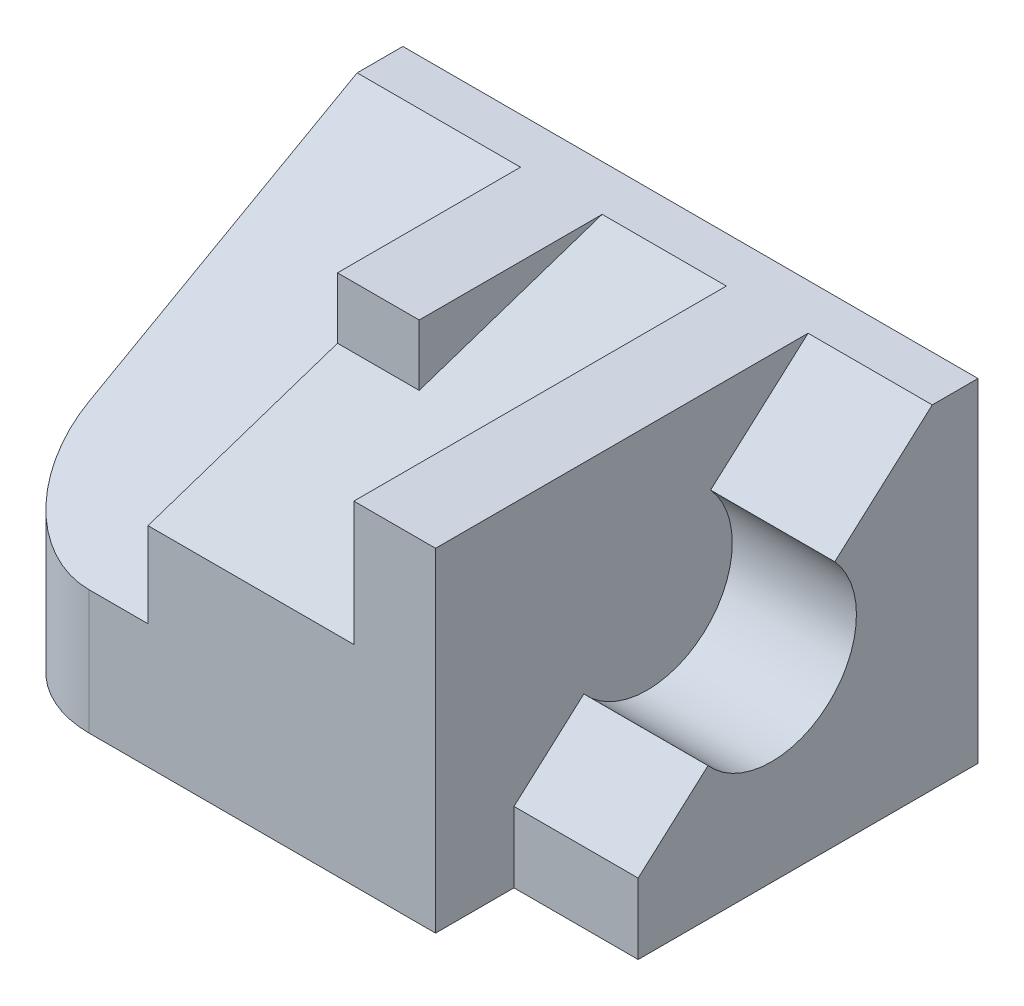
from build123d import *

# Parameters (mm, degrees)
BOSS_EXTRUDE1_DEPTH = 25.5
CUT_EXTRUDE1_DEPTH  = 12.5
CUT_EXTRUDE2_DEPTH  = 15.75
BOSS_EXTRUDE2_REACH = 27.5
SKETCH2_W           = 6.25
SKETCH2_H           = 14
CUT_EXTRUDE3_DEPTH  = 9.5
FILLET1_R           = 8


with BuildPart() as part:
    # Sketch1 → Boss-Extrude1 (new body)
    with BuildSketch(Plane(origin=(0, 0, 0), x_dir=(1, 0, 0), z_dir=(0, 1, 0))):
        Polygon((0, 0), (44, 0), (44, -26), (34.5, -26), (34.5, -32), (0, -32), align=None)
    extrude(amount=BOSS_EXTRUDE1_DEPTH)

    # Sketch3 → Cut-Extrude1 (cut)
    with BuildSketch(Plane.ZY):
        Polygon((32, 25.5), (3.5, 25.5), (32, 9.5), align=None)
    extrude(amount=-CUT_EXTRUDE1_DEPTH, mode=Mode.SUBTRACT)

    # Sketch4 → Cut-Extrude2 (cut)
    with BuildSketch(Plane.ZY.offset(-12.5)):
        Polygon((32, 25.5), (3.5, 25.5), (32, 16), align=None)
    extrude(amount=-CUT_EXTRUDE2_DEPTH, mode=Mode.SUBTRACT)

    # Boss-Extrude2: up to this face of the body (flat: up to its plane)
    boss_extrude2_end = Plane(part.part.faces().sort_by_distance((20.375, 20.75, 17.75))[0])
    # Sketch2 → Boss-Extrude2 (add, up to the picked face)
    with BuildSketch(Plane(origin=(0, 25.5, 0), x_dir=(1, 0, 0), z_dir=(0, 1, 0)), mode=Mode.PRIVATE) as boss_extrude2_sk1:
        with Locations((15.625, -10.5)):
            Rectangle(SKETCH2_W, SKETCH2_H)
    boss_extrude2_tool1 = split(extrude(boss_extrude2_sk1.sketch, amount=-BOSS_EXTRUDE2_REACH, mode=Mode.PRIVATE), bisect_by=boss_extrude2_end, keep=Keep.BOTH, mode=Mode.PRIVATE)
    add(boss_extrude2_tool1.solids().sort_by_distance((15.625, 25.5, 10.5))[0])

    # Sketch5 → Cut-Extrude3 (cut)
    with BuildSketch(Plane(origin=(44, 0, 0), x_dir=(0, 0, -1), z_dir=(1, 0, 0))):
        with BuildLine():
            Line((-10.958518779, 18.837056558), (-3.5, 25.5))
            Line((-3.5, 25.5), (-26, 25.5))
            Line((-26, 25.5), (-26, 5.4))
            Line((-26, 5.4), (-20.653405287, 10.176291277))
            ThreePointArc((-20.653405287, 10.176291277), (-11.469613255, 9.652552152), (-10.958518779, 18.837056558))
        make_face()
    extrude(amount=-CUT_EXTRUDE3_DEPTH, mode=Mode.SUBTRACT)

    # Fillet1
    fillet1_edges = [part.edges().sort_by_distance(p)[0] for p in [
        (0, 4.75, 32),
    ]]
    fillet(fillet1_edges, radius=FILLET1_R)


solid = part.part
